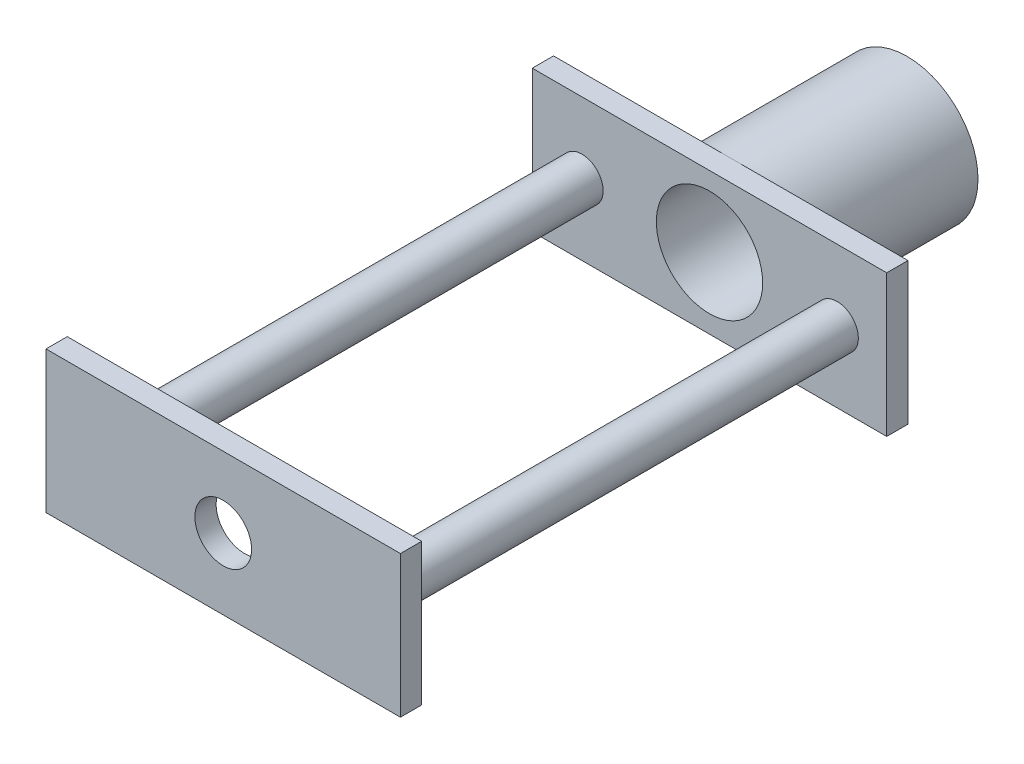
from build123d import *

# Parameters (mm, degrees)
SKETCH7_R           = 50
BOSS_EXTRUDE3_DEPTH = 124.4
SKETCH8_R           = 37.5
CUT_EXTRUDE3_DEPTH  = 56
SKETCH9_R           = 32.5
CUT_EXTRUDE4_DEPTH  = 69.4
SKETCH10_W          = 250
SKETCH10_H          = 100
BOSS_EXTRUDE4_DEPTH = 15
SKETCH11_R          = 37.5
CUT_EXTRUDE5_DEPTH  = 15
SKETCH12_R          = 15
BOSS_EXTRUDE5_DEPTH = 328
LPATTERN1_COUNT     = 2
LPATTERN1_PITCH     = 180
SKETCH13_W          = 250
SKETCH13_H          = 100
BOSS_EXTRUDE6_DEPTH = 15
SKETCH15_R          = 20
CUT_EXTRUDE6_DEPTH  = 15


with BuildPart() as part:
    # Sketch7 → Boss-Extrude3 (new body)
    with BuildSketch(Plane.XY):
        with Locations((15.572802758, -20.527785454)):
            Circle(SKETCH7_R)
    extrude(amount=BOSS_EXTRUDE3_DEPTH)

    # Sketch8 → Cut-Extrude3 (cut)
    with BuildSketch(Plane.XY.offset(124.4)):
        with Locations((15.572802758, -20.527785454)):
            Circle(SKETCH8_R)
    extrude(amount=-CUT_EXTRUDE3_DEPTH, mode=Mode.SUBTRACT)

    # Sketch9 → Cut-Extrude4 (cut)
    with BuildSketch(Plane(origin=(0, 0, 0), x_dir=(-1, 0, 0), z_dir=(0, 0, -1))):
        with Locations((-15.572802758, -20.527785454)):
            Circle(SKETCH9_R)
    extrude(amount=-CUT_EXTRUDE4_DEPTH, mode=Mode.SUBTRACT)

    # Sketch10 → Boss-Extrude4 (add)
    with BuildSketch(Plane.XY.offset(124.4)):
        with Locations((15.572802758, -20.527785454)):
            Rectangle(SKETCH10_W, SKETCH10_H)
    extrude(amount=BOSS_EXTRUDE4_DEPTH)

    # Sketch11 → Cut-Extrude5 (cut)
    with BuildSketch(Plane.XY.offset(139.4)):
        with Locations((15.572802758, -20.527785454)):
            Circle(SKETCH11_R)
    extrude(amount=-CUT_EXTRUDE5_DEPTH, mode=Mode.SUBTRACT)

    # Sketch12 → Boss-Extrude5 (add)
    with BuildSketch(Plane.XY.offset(139.4)):
        with Locations((105.572802758, -20.527785454)):
            Circle(SKETCH12_R)
    boss_extrude5 = extrude(amount=BOSS_EXTRUDE5_DEPTH)

    # LPattern1: Boss-Extrude5 ×2
    with Locations(*[(-i * LPATTERN1_PITCH, 0, 0) for i in range(1, LPATTERN1_COUNT)]):
        add(boss_extrude5)

    # Sketch13 → Boss-Extrude6 (add)
    with BuildSketch(Plane.XY.offset(467.4)):
        with Locations((15.572802758, -20.527785454)):
            Rectangle(SKETCH13_W, SKETCH13_H)
    extrude(amount=BOSS_EXTRUDE6_DEPTH)

    # Sketch15 → Cut-Extrude6 (cut)
    with BuildSketch(Plane.XY.offset(482.4)):
        with Locations((15.572802758, -20.527785454)):
            Circle(SKETCH15_R)
    extrude(amount=-CUT_EXTRUDE6_DEPTH, mode=Mode.SUBTRACT)


solid = part.part
